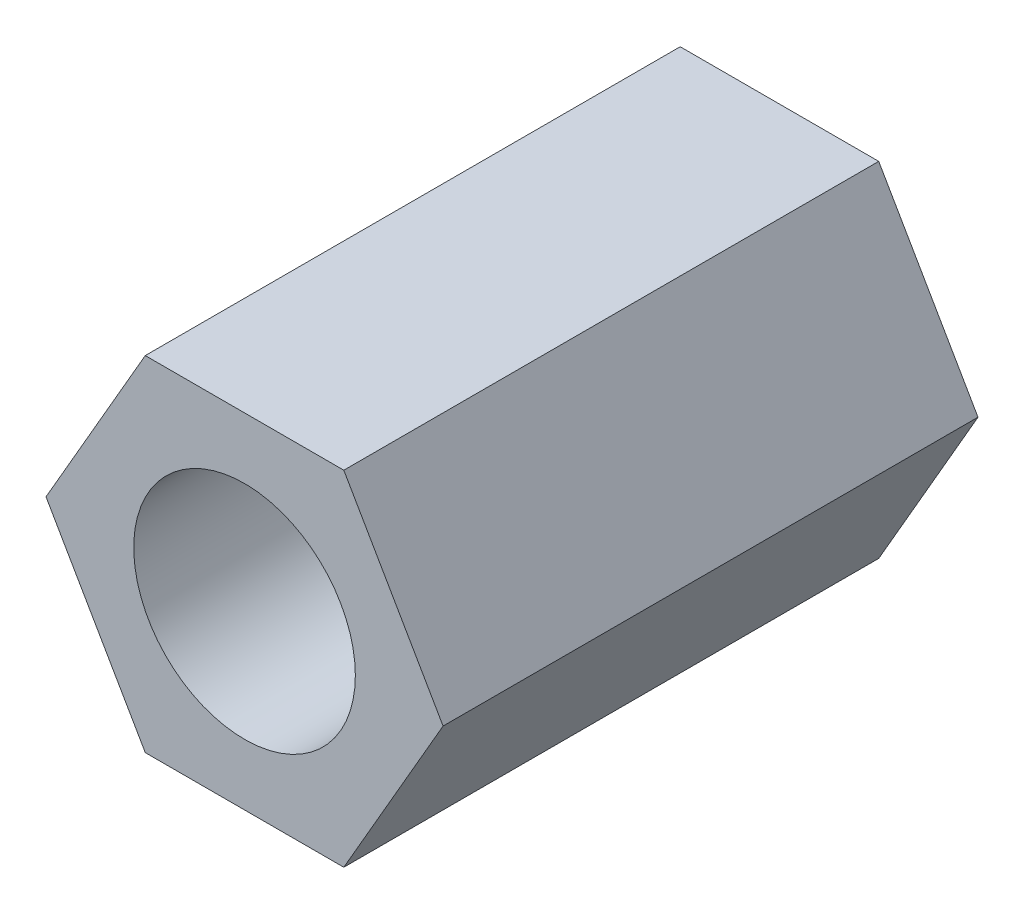
from build123d import *

# Parameters (mm, degrees)
SKETCH1_R           = 1.45
BOSS_EXTRUDE1_DEPTH = 7


with BuildPart() as part:
    # Sketch1 → Boss-Extrude1 (new body)
    with BuildSketch(Plane.XY):
        Polygon((-1.299038106, -2.25), (1.299038106, -2.25), (2.598076211, 0), (1.299038106, 2.25), (-1.299038106, 2.25), (-2.598076211, 0), align=None)
        Circle(SKETCH1_R, mode=Mode.SUBTRACT)
    extrude(amount=BOSS_EXTRUDE1_DEPTH)


solid = part.part
